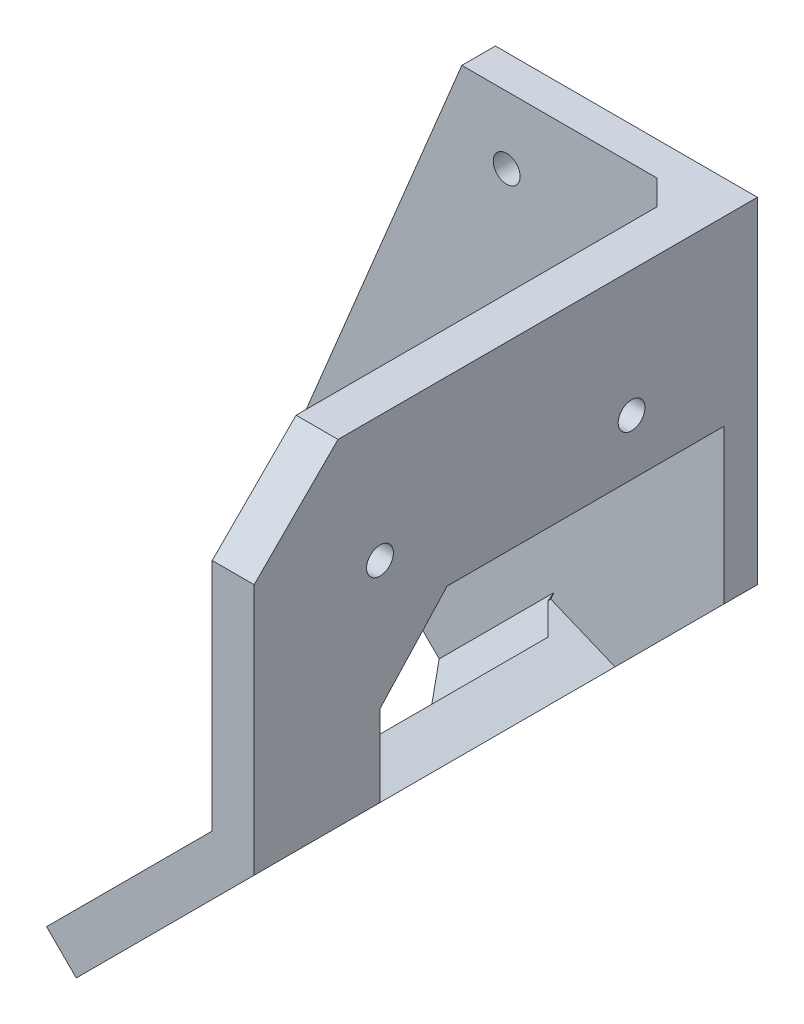
from build123d import *

# Parameters (mm, degrees)
BOSS_EXTRUDE1_DEPTH = 60
SKETCH2_R           = 1.6
BOSS_EXTRUDE2_DEPTH = 4
CHAMFER1_SIZE       = 3
SKETCH3_R           = 1.6
CUT_EXTRUDE1_DEPTH  = 8
SKETCH4_R           = 1.6
CUT_EXTRUDE2_DEPTH  = 8
CHAMFER2_SIZE       = 10
CUT_EXTRUDE3_DEPTH  = 40


with BuildPart() as part:
    # Sketch1 → Boss-Extrude1 (new body)
    with BuildSketch(Plane.XY):
        Polygon((225, -175), (225, -135), (220, -135), (220, -172.928932188), (193.180194847, -199.748737342), (196.715728753, -203.284271247), align=None)
    extrude(amount=BOSS_EXTRUDE1_DEPTH)

    # Sketch2 → Boss-Extrude2 (add)
    with BuildSketch(Plane(origin=(0, 0, 0), x_dir=(-1, 0, 0), z_dir=(0, 0, -1))):
        Polygon((-225, -135), (-193.759605749, -135), (-174.625434131, -181.193976626), (-196.715728753, -203.284271247), (-225, -175), align=None)
        with Locations((-207.289508253, -167.664074122)):
            Circle(SKETCH2_R, mode=Mode.SUBTRACT)
        with Locations((-184.062077547, -179.316911543)):
            Circle(SKETCH2_R, mode=Mode.SUBTRACT)
        with Locations((-199.105034852, -143)):
            Circle(SKETCH2_R, mode=Mode.SUBTRACT)
    extrude(amount=-BOSS_EXTRUDE2_DEPTH)

    # Chamfer1
    chamfer1_edges = [part.edges().sort_by_distance(p)[0] for p in [
        (220, -153.964466094, 4),
        (206.590097423, -186.338834765, 4),
    ]]
    chamfer(chamfer1_edges, length=CHAMFER1_SIZE)

    # Sketch3 → Cut-Extrude1 (cut)
    with BuildSketch(Plane(origin=(225, 0, 0), x_dir=(0, 0, -1), z_dir=(1, 0, 0))):
        with Locations((-45, -150)):
            Circle(SKETCH3_R)
        with Locations((-15, -150)):
            Circle(SKETCH3_R)
    extrude(amount=-CUT_EXTRUDE1_DEPTH, mode=Mode.SUBTRACT)

    # Sketch4 → Cut-Extrude2 (cut)
    with BuildSketch(Plane(origin=(200, -200, 0), x_dir=(0, 0, -1), z_dir=(0.707106781, -0.707106781, 0))):
        with Locations((-45, 10.355339059)):
            Circle(SKETCH4_R)
        with Locations((-15, 10.355339059)):
            Circle(SKETCH4_R)
    extrude(amount=-CUT_EXTRUDE2_DEPTH, mode=Mode.SUBTRACT)

    # Chamfer2
    chamfer2_edges = [part.edges().sort_by_distance(p)[0] for p in [
        (222.5, -135, 60),
        (194.9479618, -201.516504294, 60),
    ]]
    chamfer(chamfer2_edges, length=CHAMFER2_SIZE)

    # Sketch5 → Cut-Extrude3 (cut)
    with BuildSketch(Plane(origin=(239.779220614, -99.319805153, 0), x_dir=(0, 0, -1), z_dir=(0.923879533, -0.382683432, 0))):
        Polygon((-37, -58.619964607), (-45, -66.619964607), (-45, -84.530327208), (-37, -92.530327208), (-4, -92.530327208), (-4, -58.619964607), align=None)
    extrude(amount=CUT_EXTRUDE3_DEPTH, mode=Mode.SUBTRACT)


solid = part.part
